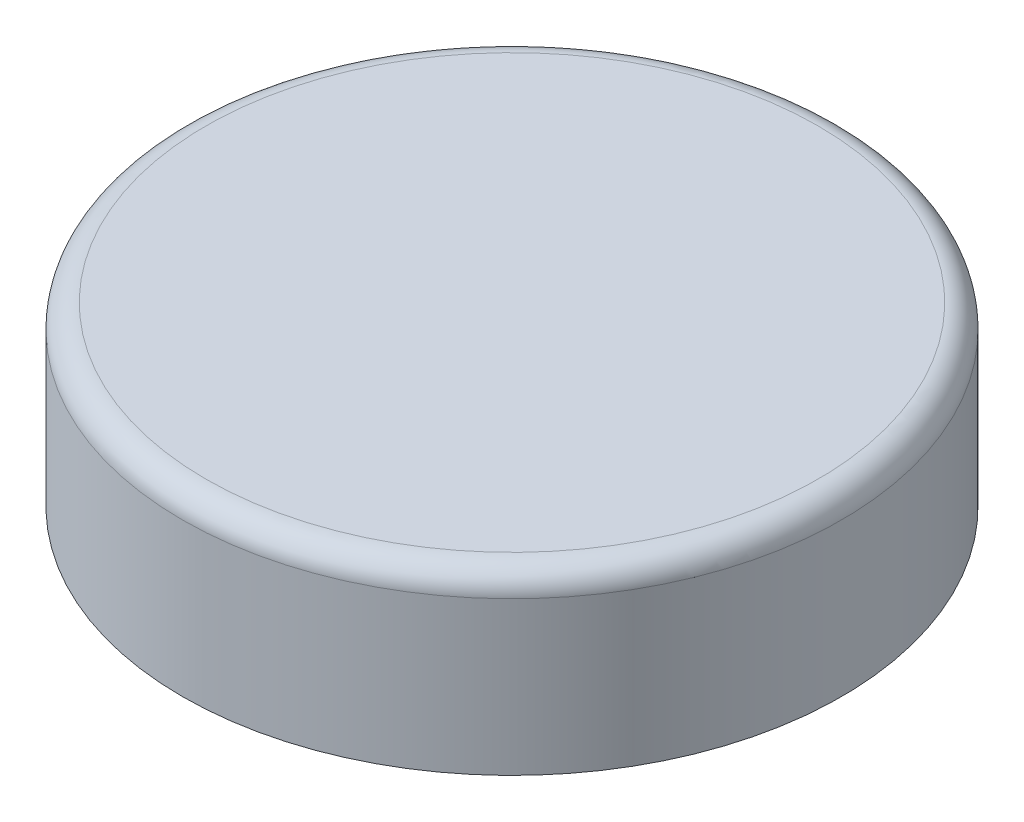
from build123d import *

# Parameters (mm, degrees)
SKETCH1_R           = 28
SKETCH1_R_2         = 25
BOSS_EXTRUDE1_DEPTH = 15
SKETCH2_R           = 25.289752038
BOSS_EXTRUDE2_DEPTH = 1.5
FILLET1_R           = 2


with BuildPart() as part:
    # Sketch1 → Boss-Extrude1 (new body)
    with BuildSketch(Plane(origin=(0, 0, 0), x_dir=(1, 0, 0), z_dir=(0, 1, 0))):
        Circle(SKETCH1_R)
        Circle(SKETCH1_R_2, mode=Mode.SUBTRACT)
    extrude(amount=BOSS_EXTRUDE1_DEPTH)

    # Sketch2 → Boss-Extrude2 (add)
    with BuildSketch(Plane(origin=(0, 15, 0), x_dir=(1, 0, 0), z_dir=(0, 1, 0))):
        Circle(SKETCH2_R)
    extrude(amount=-BOSS_EXTRUDE2_DEPTH)

    # Fillet1
    fillet1_edges = [part.edges().sort_by_distance(p)[0] for p in [
        (-28, 15, 0),
    ]]
    fillet(fillet1_edges, radius=FILLET1_R)


solid = part.part
